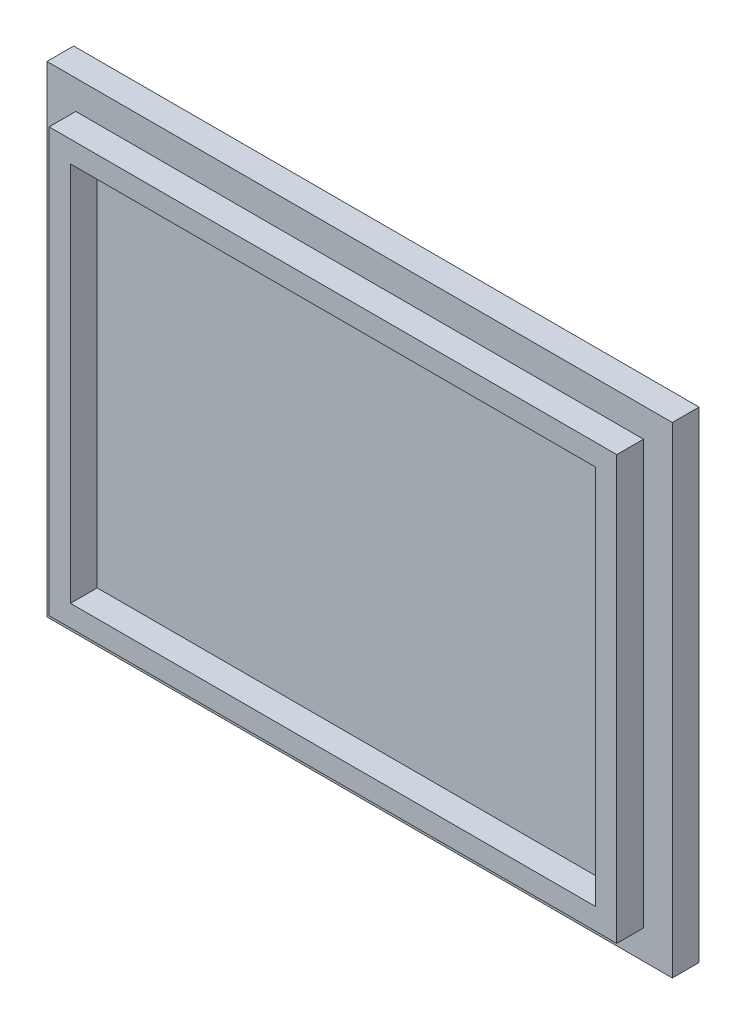
from build123d import *

# Parameters (mm, degrees)
SKETCH1_W           = 148.59
SKETCH1_H           = 114.3
BOSS_EXTRUDE1_DEPTH = 6.35
SKETCH2_W           = 134.874
SKETCH2_H           = 100.584
SKETCH2_W_2         = 124.714
SKETCH2_H_2         = 90.424
BOSS_EXTRUDE2_DEPTH = 6.35


with BuildPart() as part:
    # Sketch1 → Boss-Extrude1 (new body)
    with BuildSketch(Plane.XY):
        Rectangle(SKETCH1_W, SKETCH1_H)
    extrude(amount=BOSS_EXTRUDE1_DEPTH)

    # Sketch2 → Boss-Extrude2 (add)
    with BuildSketch(Plane.XY.offset(6.35)):
        Rectangle(SKETCH2_W, SKETCH2_H)
        Rectangle(SKETCH2_W_2, SKETCH2_H_2, mode=Mode.SUBTRACT)
    extrude(amount=BOSS_EXTRUDE2_DEPTH)


solid = part.part
